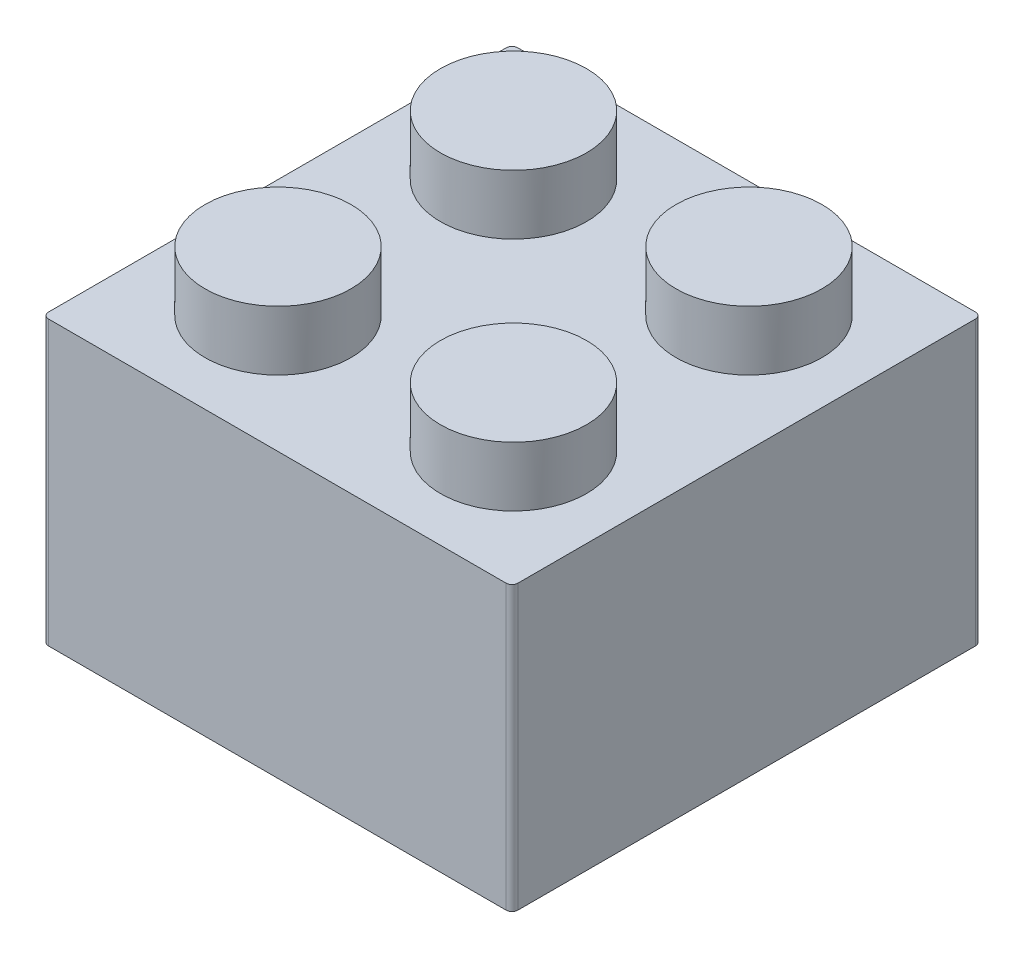
from build123d import *

# Parameters (mm, degrees)
SKETCH1_W           = 15.75
SKETCH1_H           = 15.75
BOSS_EXTRUDE1_DEPTH = 4.75
SKETCH2_R           = 2.45
BOSS_EXTRUDE2_DEPTH = 2
SKETCH4_W           = 12.9
SKETCH4_H           = 12.9
CUT_EXTRUDE1_DEPTH  = 4
SKETCH5_R           = 3.25
SKETCH5_R_2         = 2.45
BOSS_EXTRUDE3_DEPTH = 4
FILLET1_R           = 0.2


with BuildPart() as part:
    # Sketch1 → Boss-Extrude1 (new body, symmetric)
    with BuildSketch(Plane(origin=(0, 0, 0), x_dir=(1, 0, 0), z_dir=(0, 1, 0))):
        with Locations((7.875, 7.875)):
            Rectangle(SKETCH1_W, SKETCH1_H)
    extrude(amount=BOSS_EXTRUDE1_DEPTH, both=True)

    # Sketch2 → Boss-Extrude2 (add)
    with BuildSketch(Plane(origin=(0, 4.75, 0), x_dir=(1, 0, 0), z_dir=(0, 1, 0))):
        with Locations((3.95, 3.95)):
            Circle(SKETCH2_R)
        with Locations((11.85, 3.95)):
            Circle(SKETCH2_R)
        with Locations((11.85, 11.85)):
            Circle(SKETCH2_R)
        with Locations((3.95, 11.85)):
            Circle(SKETCH2_R)
    extrude(amount=BOSS_EXTRUDE2_DEPTH)

    # Sketch4 → Cut-Extrude1 (cut)
    with BuildSketch(Plane.XZ.offset(4.75)):
        with Locations((7.9, -7.9)):
            Rectangle(SKETCH4_W, SKETCH4_H)
    extrude(amount=-CUT_EXTRUDE1_DEPTH, mode=Mode.SUBTRACT)

    # Sketch5 → Boss-Extrude3 (add)
    with BuildSketch(Plane.XZ.offset(0.75)):
        with Locations((7.9, -7.9)):
            Circle(SKETCH5_R)
        with Locations((7.9, -7.9)):
            Circle(SKETCH5_R_2, mode=Mode.SUBTRACT)
    extrude(amount=BOSS_EXTRUDE3_DEPTH)

    # Fillet1
    fillet1_edges = [part.edges().sort_by_distance(p)[0] for p in [
        (0, 0, -15.75),
        (15.75, 0, -15.75),
        (15.75, 0, 0),
        (0, 0, 0),
    ]]
    fillet(fillet1_edges, radius=FILLET1_R)


solid = part.part
